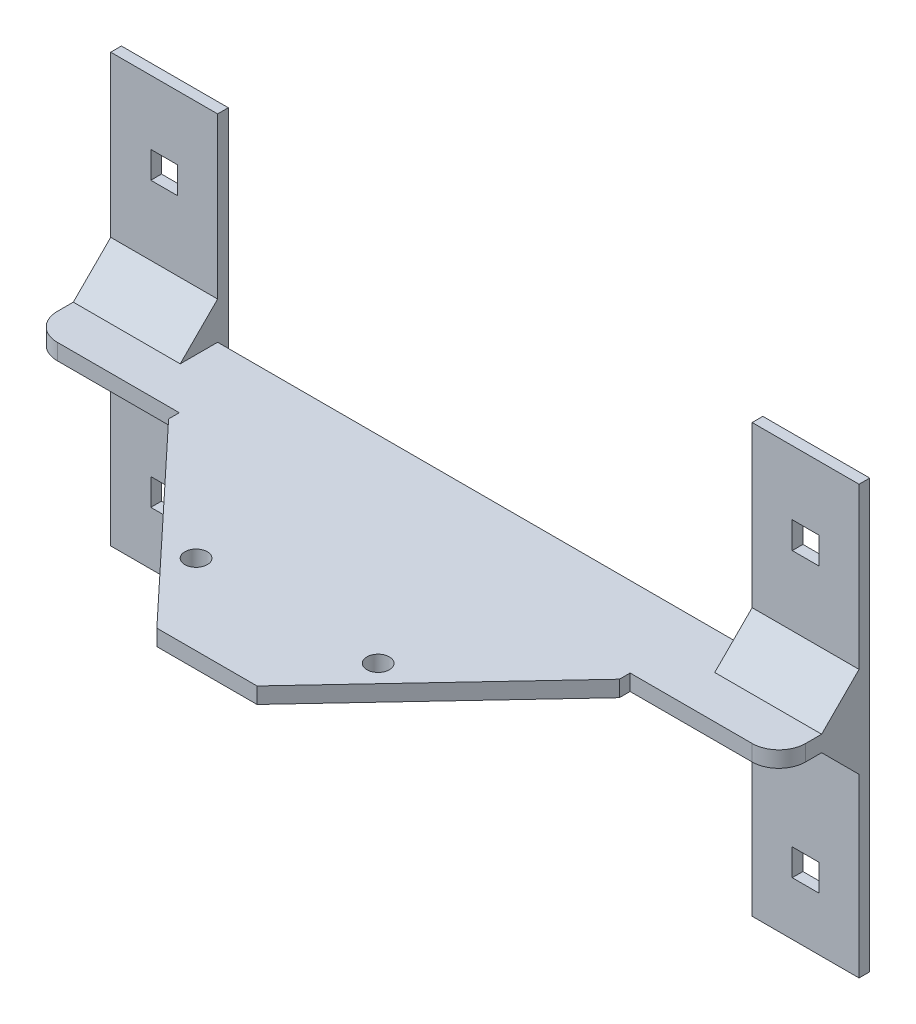
from build123d import *

# Parameters (mm, degrees)
SKETCH4_R           = 2.1
BOSS_EXTRUDE3_DEPTH = 1.2
SKETCH5_W           = 84.339489928
SKETCH5_H           = 2
BOSS_EXTRUDE4_DEPTH = 2.4
SKETCH6_R           = 2.1
BOSS_EXTRUDE5_DEPTH = 1.2
SKETCH7_W           = 104.067802039
SKETCH7_H           = 60.652447956
CUT_EXTRUDE1_DEPTH  = 3.6
BOSS_EXTRUDE6_DEPTH = 1.2
CUT_EXTRUDE2_DEPTH  = 10
SKETCH10_R          = 2.1
BOSS_EXTRUDE7_DEPTH = 1.8
SKETCH11_W          = 20
SKETCH11_H          = 37
SKETCH11_H_2        = 40
SKETCH11_H_3        = 3
BOSS_EXTRUDE8_DEPTH = 2
SKETCH12_W          = 5
SKETCH12_H          = 5
CUT_EXTRUDE3_DEPTH  = 22
CHAMFER2_SIZE       = 7
FILLET1_R           = 5


with BuildPart() as part:
    # Sketch4 → Boss-Extrude3 (new body)
    with BuildSketch(Plane(origin=(0, 0, 0), x_dir=(1, 0, 0), z_dir=(0, 1, 0))):
        Polygon((39.4127274, 47.640295112), (-2.757017564, 47.640295112), (-2.757017564, 45.640295112), (39.4127274, 0.640295112), align=None)
        with Locations((22.381300815, 25.64100497)):
            Circle(SKETCH4_R, mode=Mode.SUBTRACT)
        Polygon((81.582472364, 47.640295112), (39.4127274, 47.640295112), (39.4127274, 0.640295112), (81.582472364, 45.640295112), align=None)
        with Locations((56.444153985, 25.64100497)):
            Circle(SKETCH4_R, mode=Mode.SUBTRACT)
    extrude(amount=BOSS_EXTRUDE3_DEPTH)

    # Sketch5 → Boss-Extrude4 (add)
    with BuildSketch(Plane(origin=(0, 0, 0), x_dir=(-1, 0, 0), z_dir=(0, -1, 0))):
        with Locations((-39.4127274, 46.640295112)):
            Rectangle(SKETCH5_W, SKETCH5_H)
    extrude(amount=BOSS_EXTRUDE4_DEPTH)

    # Sketch6 → Boss-Extrude5 (add)
    with BuildSketch(Plane(origin=(0, -2.4, 0), x_dir=(-1, 0, 0), z_dir=(0, -1, 0))):
        Polygon((2.757017564, 47.640295112), (-81.582472364, 47.640295112), (-81.582472364, 45.640295112), (-39.4127274, 0.640295112), (2.757017564, 45.640295112), align=None)
        with Locations((-22.381300815, 25.64100497)):
            Circle(SKETCH6_R, mode=Mode.SUBTRACT)
        with Locations((-56.444153985, 25.64100497)):
            Circle(SKETCH6_R, mode=Mode.SUBTRACT)
    extrude(amount=BOSS_EXTRUDE5_DEPTH)

    # Sketch7 → Cut-Extrude1 (cut)
    with BuildSketch(Plane(origin=(0, -3.6, 0), x_dir=(-1, 0, 0), z_dir=(0, -1, 0))):
        with Locations((-36.785683682, 25.144953811)):
            Rectangle(SKETCH7_W, SKETCH7_H)
    extrude(amount=-CUT_EXTRUDE1_DEPTH, mode=Mode.SUBTRACT)

    # Sketch8 → Boss-Extrude6 (add)
    with BuildSketch(Plane(origin=(0, 1.2, 0), x_dir=(1, 0, 0), z_dir=(0, 1, 0))):
        Polygon((-2.757017564, 47.640295112), (39.4127274, 47.640295112), (39.4127274, 62.640295112), (-30.5872726, 62.640295112), (-30.5872726, 47.640295112), align=None)
        Polygon((81.582472364, 47.640295112), (109.4127274, 47.640295112), (109.4127274, 62.640295112), (39.4127274, 62.640295112), (39.4127274, 47.640295112), align=None)
    extrude(amount=-BOSS_EXTRUDE6_DEPTH)

    # Sketch9 → Cut-Extrude2 (cut)
    with BuildSketch(Plane(origin=(0, 1.2, 0), x_dir=(1, 0, 0), z_dir=(0, 1, 0))):
        Polygon((30.041672963, 10.640295112), (48.783781837, 10.640295112), (39.4127274, 0.640295112), align=None)
    extrude(amount=-CUT_EXTRUDE2_DEPTH, mode=Mode.SUBTRACT)

    # Sketch10 → Boss-Extrude7 (add)
    with BuildSketch(Plane(origin=(0, 1.2, 0), x_dir=(1, 0, 0), z_dir=(0, 1, 0))):
        Polygon((-2.757017564, 47.640295112), (-2.757017564, 45.640295112), (30.041672963, 10.640295112), (48.783781837, 10.640295112), (81.582472364, 45.640295112), (81.582472364, 47.640295112), (109.4127274, 47.640295112), (109.4127274, 62.640295112), (-30.5872726, 62.640295112), (-30.5872726, 47.640295112), align=None)
        with Locations((22.381300815, 25.64100497)):
            Circle(SKETCH10_R, mode=Mode.SUBTRACT)
        with Locations((56.444153985, 25.64100497)):
            Circle(SKETCH10_R, mode=Mode.SUBTRACT)
    extrude(amount=BOSS_EXTRUDE7_DEPTH)

    # Sketch11 → Boss-Extrude8 (add)
    with BuildSketch(Plane(origin=(0, 0, -62.640295112), x_dir=(-1, 0, 0), z_dir=(0, 0, -1))):
        with Locations((-99.4127274, 21.5)):
            Rectangle(SKETCH11_W, SKETCH11_H)
        with Locations((-99.4127274, -20)):
            Rectangle(SKETCH11_W, SKETCH11_H_2)
        with Locations((-99.4127274, 1.5)):
            Rectangle(SKETCH11_W, SKETCH11_H_3)
        with Locations((20.5872726, 21.5)):
            Rectangle(SKETCH11_W, SKETCH11_H)
        with Locations((20.5872726, 1.5)):
            Rectangle(SKETCH11_W, SKETCH11_H_3)
        with Locations((20.5872726, -20)):
            Rectangle(SKETCH11_W, SKETCH11_H_2)
    extrude(amount=BOSS_EXTRUDE8_DEPTH)

    # Sketch12 → Cut-Extrude3 (cut)
    with BuildSketch(Plane(origin=(0, 0, -64.640295112), x_dir=(-1, 0, 0), z_dir=(0, 0, -1))):
        with Locations((-99.4127274, 25.5)):
            Rectangle(SKETCH12_W, SKETCH12_H)
        with Locations((-99.4127274, -27.5)):
            Rectangle(SKETCH12_W, SKETCH12_H)
        with Locations((20.5872726, -27.5)):
            Rectangle(SKETCH12_W, SKETCH12_H)
        with Locations((20.5872726, 25.5)):
            Rectangle(SKETCH12_W, SKETCH12_H)
    extrude(amount=-CUT_EXTRUDE3_DEPTH, mode=Mode.SUBTRACT)

    # Chamfer2
    chamfer2_edges = [part.edges().sort_by_distance(p)[0] for p in [
        (-20.5872726, 0, -62.640295112),
        (99.4127274, 3, -62.640295112),
        (99.4127274, 0, -62.640295112),
        (-20.5872726, 3, -62.640295112),
    ]]
    chamfer(chamfer2_edges, length=CHAMFER2_SIZE)

    # Fillet1
    fillet1_edges = [part.edges().sort_by_distance(p)[0] for p in [
        (109.4127274, 1.5, -47.640295112),
        (-30.5872726, 1.5, -47.640295112),
    ]]
    fillet(fillet1_edges, radius=FILLET1_R)


solid = part.part
